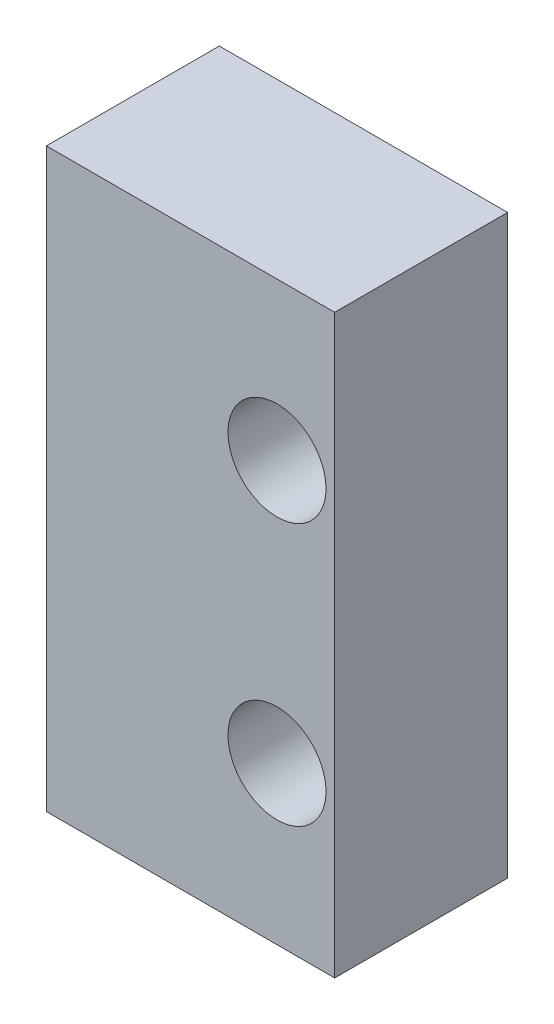
from build123d import *

# Parameters (mm, degrees)
ESQUISSE1_W        = 10
ESQUISSE1_H        = 20
ESQUISSE1_R        = 1.7
BOSS_EXTRU_1_DEPTH = 3


with BuildPart() as part:
    # Esquisse1 → Boss.-Extru.1 (new body, symmetric)
    with BuildSketch(Plane.XY):
        Rectangle(ESQUISSE1_W, ESQUISSE1_H)
        with Locations((3, 4.55)):
            Circle(ESQUISSE1_R, mode=Mode.SUBTRACT)
        with Locations((3, -4.55)):
            Circle(ESQUISSE1_R, mode=Mode.SUBTRACT)
    extrude(amount=BOSS_EXTRU_1_DEPTH, both=True)


solid = part.part
